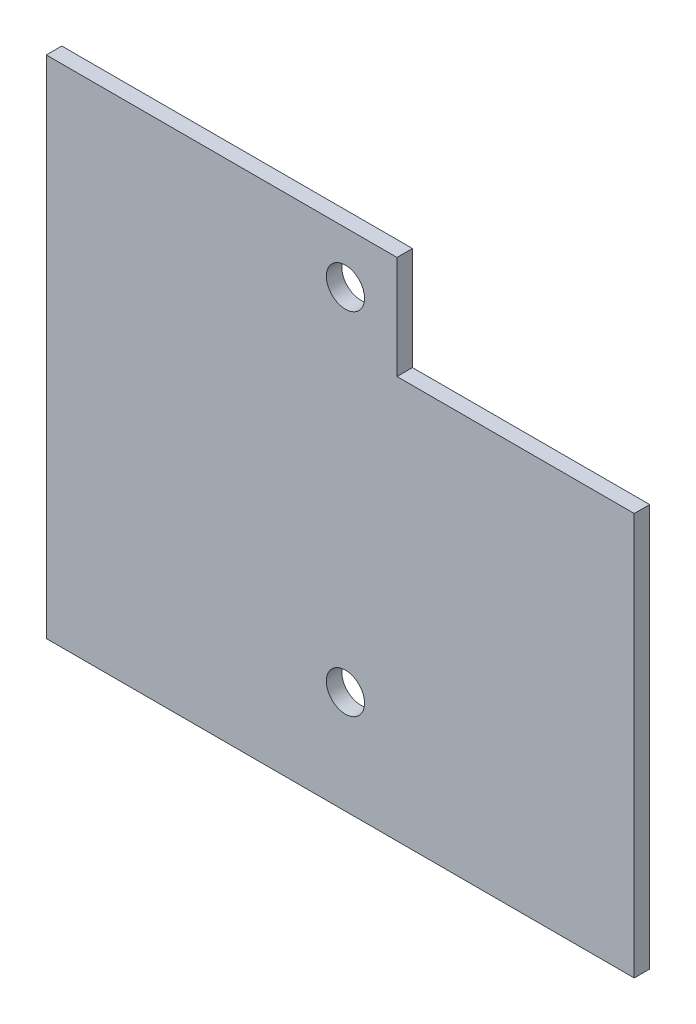
from build123d import *

# Parameters (mm, degrees)
SKETCH_1_R      = 1.85
EXTRUDE_1_DEPTH = 1.5


with BuildPart() as part:
    # Эскиз1 → Вытянуть1 (new body)
    with BuildSketch(Plane.XY):
        Polygon((0, 0), (0, 49), (34, 49), (34, 39), (57, 39), (57, 0), align=None)
        with Locations((29, 44)):
            Circle(SKETCH_1_R, mode=Mode.SUBTRACT)
        with Locations((29, 10)):
            Circle(SKETCH_1_R, mode=Mode.SUBTRACT)
    extrude(amount=EXTRUDE_1_DEPTH)


solid = part.part
